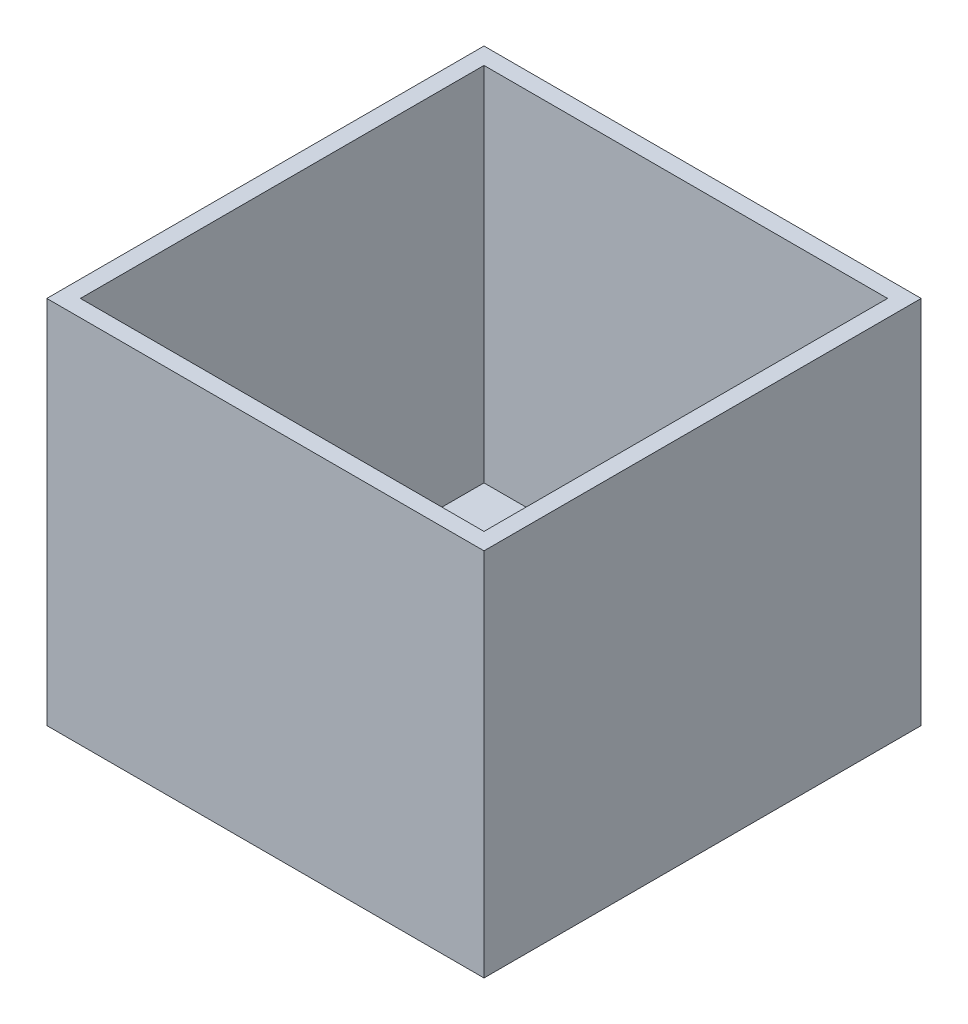
from build123d import *

# Parameters (mm, degrees)
SKETCH1_W           = 330.2
SKETCH1_H           = 330.2
BOSS_EXTRUDE1_DEPTH = 279.4
SKETCH2_W           = 304.8
SKETCH2_H           = 304.8
CUT_EXTRUDE1_DEPTH  = 273.05


with BuildPart() as part:
    # Sketch1 → Boss-Extrude1 (new body)
    with BuildSketch(Plane(origin=(0, 0, 0), x_dir=(1, 0, 0), z_dir=(0, 1, 0))):
        Rectangle(SKETCH1_W, SKETCH1_H)
    extrude(amount=BOSS_EXTRUDE1_DEPTH)

    # Sketch2 → Cut-Extrude1 (cut)
    with BuildSketch(Plane(origin=(0, 279.4, 0), x_dir=(1, 0, 0), z_dir=(0, 1, 0))):
        Rectangle(SKETCH2_W, SKETCH2_H)
    extrude(amount=-CUT_EXTRUDE1_DEPTH, mode=Mode.SUBTRACT)


solid = part.part
